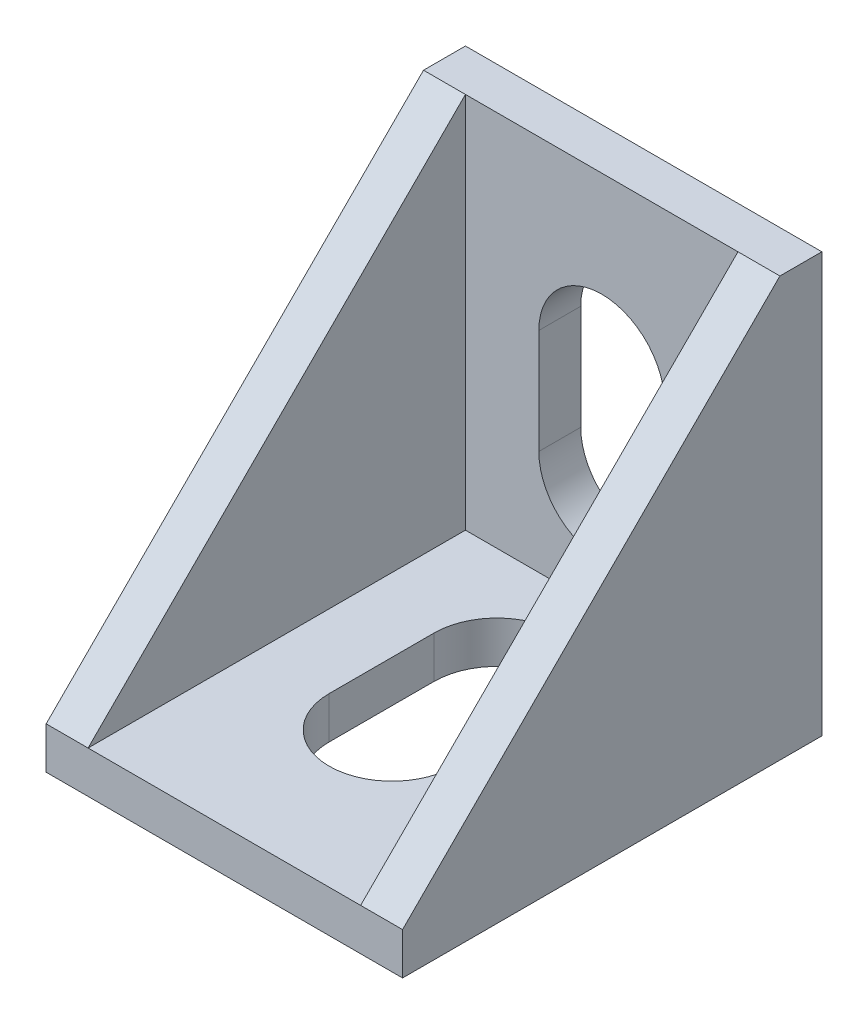
from build123d import *

# Parameters (mm, degrees)
SKETCH1_W               = 17
SKETCH1_H               = 20
BOSS_EXTRUDE1_DEPTH     = 20
SKETCH2_W               = 13
SKETCH2_H               = 18
CUT_EXTRUDE1_DEPTH      = 18
CUT_EXTRUDE2_DEPTH      = 1
CUT_EXTRUDE2_DEPTH_BACK = 18
CUT_EXTRUDE3_REACH      = 4
CUT_EXTRUDE4_REACH      = 4
BOSS_EXTRUDE2_DEPTH     = 1
BOSS_EXTRUDE3_DEPTH     = 1


with BuildPart() as part:
    # Sketch1 → Boss-Extrude1 (new body)
    with BuildSketch(Plane.XY):
        Rectangle(SKETCH1_W, SKETCH1_H)
    extrude(amount=BOSS_EXTRUDE1_DEPTH)

    # Sketch2 → Cut-Extrude1 (cut)
    with BuildSketch(Plane(origin=(0, 10, 0), x_dir=(1, 0, 0), z_dir=(0, 1, 0))):
        with Locations((0, -11)):
            Rectangle(SKETCH2_W, SKETCH2_H)
    extrude(amount=-CUT_EXTRUDE1_DEPTH, mode=Mode.SUBTRACT)

    # Sketch3 → Cut-Extrude2 (cut, two sides)
    with BuildSketch(Plane(origin=(8.5, 0, 0), x_dir=(0, 0, -1), z_dir=(1, 0, 0))) as cut_extrude2_sk:
        Polygon((-2, 10), (-20, -8), (-20, 10), align=None)
    extrude(amount=CUT_EXTRUDE2_DEPTH, mode=Mode.SUBTRACT)
    extrude(cut_extrude2_sk.sketch, amount=-CUT_EXTRUDE2_DEPTH_BACK, mode=Mode.SUBTRACT)

    # Sketch4 → Cut-Extrude3 (cut, up to next)
    with BuildSketch(Plane(origin=(0, -8, 0), x_dir=(1, 0, 0), z_dir=(0, 1, 0)), mode=Mode.PRIVATE) as cut_extrude3_sk1:
        with BuildLine():
            Line((-3, -12), (-3, -7))
            ThreePointArc((-3, -7), (0, -4), (3, -7))
            Line((3, -7), (3, -12))
            ThreePointArc((3, -12), (0, -15), (-3, -12))
        make_face()
    cut_extrude3_tool1 = extrude(cut_extrude3_sk1.sketch, amount=-CUT_EXTRUDE3_REACH, mode=Mode.PRIVATE) & part.part
    add(cut_extrude3_tool1.solids().sort_by_distance((0, -8, 9.5))[0], mode=Mode.SUBTRACT)

    # Sketch5 → Cut-Extrude4 (cut, up to next)
    with BuildSketch(Plane.XY.offset(2), mode=Mode.PRIVATE) as cut_extrude4_sk1:
        with BuildLine():
            Line((-3, -3), (-3, 2))
            ThreePointArc((-3, 2), (0, 5), (3, 2))
            Line((3, 2), (3, -3))
            ThreePointArc((3, -3), (0, -6), (-3, -3))
        make_face()
    cut_extrude4_tool1 = extrude(cut_extrude4_sk1.sketch, amount=-CUT_EXTRUDE4_REACH, mode=Mode.PRIVATE) & part.part
    add(cut_extrude4_tool1.solids().sort_by_distance((0, -0.5, 2))[0], mode=Mode.SUBTRACT)

    # Sketch6 → Boss-Extrude2 (add)
    with BuildSketch(Plane.XZ.offset(10)):
        with BuildLine():
            Line((-1, 19), (1, 19))
            ThreePointArc((1, 19), (2, 18), (1, 17))
            Line((1, 17), (-1, 17))
            ThreePointArc((-1, 17), (-2, 18), (-1, 19))
        make_face()
        with BuildLine():
            Line((-1, 3), (1, 3))
            ThreePointArc((1, 3), (2, 2), (1, 1))
            Line((1, 1), (-1, 1))
            ThreePointArc((-1, 1), (-2, 2), (-1, 3))
        make_face()
    extrude(amount=BOSS_EXTRUDE2_DEPTH)

    # Sketch7 → Boss-Extrude3 (add)
    with BuildSketch(Plane(origin=(0, 0, 0), x_dir=(-1, 0, 0), z_dir=(0, 0, -1))):
        with BuildLine():
            Line((1, -9), (-1, -9))
            ThreePointArc((-1, -9), (-2, -8), (-1, -7))
            Line((-1, -7), (1, -7))
            ThreePointArc((1, -7), (2, -8), (1, -9))
        make_face()
        with BuildLine():
            Line((1, 7), (-1, 7))
            ThreePointArc((-1, 7), (-2, 8), (-1, 9))
            Line((-1, 9), (1, 9))
            ThreePointArc((1, 9), (2, 8), (1, 7))
        make_face()
    extrude(amount=BOSS_EXTRUDE3_DEPTH)


solid = part.part
